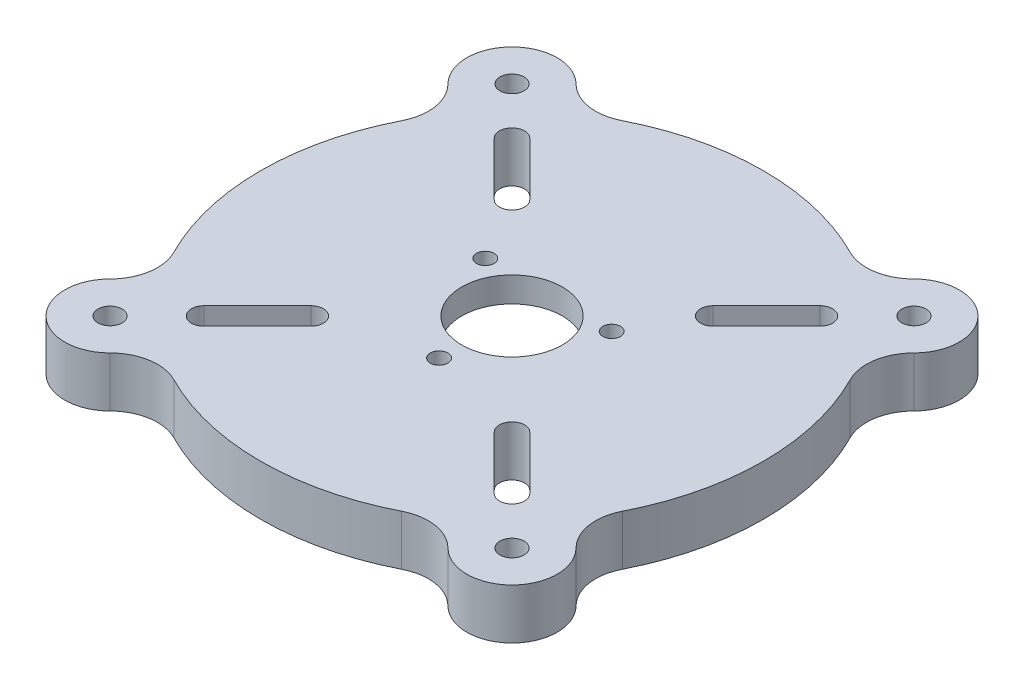
from build123d import *

# Parameters (mm, degrees)
SKETCH1_R           = 2.4
BOSS_EXTRUDE2_DEPTH = 10
SKETCH2_R           = 21.25
SKETCH2_R_2         = 1.75
SKETCH2_R_3         = 10
CUT_EXTRUDE3_DEPTH  = 5
SKETCH2_2_R         = 1.75
SKETCH2_2_R_2       = 10
CUT_EXTRUDE4_DEPTH  = 72.414284285


with BuildPart() as part:
    # Sketch1 → Boss-Extrude2 (new body)
    with BuildSketch(Plane(origin=(0, 0, 0), x_dir=(1, 0, 0), z_dir=(0, 1, 0))):
        with BuildLine():
            ThreePointArc((44.576420667, -22.648238795), (50, 0), (44.576420667, 22.648238795))
            ThreePointArc((44.576420667, 22.648238795), (43.670494672, 28.400158503), (46.315494168, 33.587572106))
            ThreePointArc((46.315494168, 33.587572106), (46.315494168, 46.315494168), (33.587572106, 46.315494168))
            ThreePointArc((33.587572106, 46.315494168), (28.400158503, 43.670494672), (22.648238795, 44.576420667))
            ThreePointArc((22.648238795, 44.576420667), (0, 50), (-22.648238795, 44.576420667))
            ThreePointArc((-22.648238795, 44.576420667), (-28.400158503, 43.670494672), (-33.587572106, 46.315494168))
            ThreePointArc((-33.587572106, 46.315494168), (-46.315494168, 46.315494168), (-46.315494168, 33.587572106))
            ThreePointArc((-46.315494168, 33.587572106), (-43.670494672, 28.400158503), (-44.576420667, 22.648238795))
            ThreePointArc((-44.576420667, 22.648238795), (-50, 0), (-44.576420667, -22.648238795))
            ThreePointArc((-44.576420667, -22.648238795), (-43.670494672, -28.400158503), (-46.315494168, -33.587572106))
            ThreePointArc((-46.315494168, -33.587572106), (-46.315494168, -46.315494168), (-33.587572106, -46.315494168))
            ThreePointArc((-33.587572106, -46.315494168), (-28.400158503, -43.670494672), (-22.648238795, -44.576420667))
            ThreePointArc((-22.648238795, -44.576420667), (0, -50), (22.648238795, -44.576420667))
            ThreePointArc((22.648238795, -44.576420667), (28.400158503, -43.670494672), (33.587572106, -46.315494168))
            ThreePointArc((33.587572106, -46.315494168), (46.315494168, -46.315494168), (46.315494168, -33.587572106))
            ThreePointArc((46.315494168, -33.587572106), (43.670494672, -28.400158503), (44.576420667, -22.648238795))
        make_face()
        with BuildLine():
            ThreePointArc((-21.767766953, -18.232233047), (-18.232233047, -18.232233047), (-18.232233047, -21.767766953))
            Line((-18.232233047, -21.767766953), (-28.838834765, -32.374368671))
            ThreePointArc((-28.838834765, -32.374368671), (-32.374368671, -32.374368671), (-32.374368671, -28.838834765))
            Line((-32.374368671, -28.838834765), (-21.767766953, -18.232233047))
        make_face(mode=Mode.SUBTRACT)
        with BuildLine():
            ThreePointArc((18.232233047, -21.767766953), (18.232233047, -18.232233047), (21.767766953, -18.232233047))
            Line((21.767766953, -18.232233047), (32.374368671, -28.838834765))
            ThreePointArc((32.374368671, -28.838834765), (32.374368671, -32.374368671), (28.838834765, -32.374368671))
            Line((28.838834765, -32.374368671), (18.232233047, -21.767766953))
        make_face(mode=Mode.SUBTRACT)
        with BuildLine():
            ThreePointArc((-18.232233047, 21.767766953), (-18.232233047, 18.232233047), (-21.767766953, 18.232233047))
            Line((-21.767766953, 18.232233047), (-32.374368671, 28.838834765))
            ThreePointArc((-32.374368671, 28.838834765), (-32.374368671, 32.374368671), (-28.838834765, 32.374368671))
            Line((-28.838834765, 32.374368671), (-18.232233047, 21.767766953))
        make_face(mode=Mode.SUBTRACT)
        with BuildLine():
            ThreePointArc((21.767766953, 18.232233047), (18.232233047, 18.232233047), (18.232233047, 21.767766953))
            Line((18.232233047, 21.767766953), (28.838834765, 32.374368671))
            ThreePointArc((28.838834765, 32.374368671), (32.374368671, 32.374368671), (32.374368671, 28.838834765))
            Line((32.374368671, 28.838834765), (21.767766953, 18.232233047))
        make_face(mode=Mode.SUBTRACT)
        with Locations((39.951533137, -39.951533137)):
            Circle(SKETCH1_R, mode=Mode.SUBTRACT)
        with Locations((-39.951533137, -39.951533137)):
            Circle(SKETCH1_R, mode=Mode.SUBTRACT)
        with Locations((-39.951533137, 39.951533137)):
            Circle(SKETCH1_R, mode=Mode.SUBTRACT)
        with Locations((39.951533137, 39.951533137)):
            Circle(SKETCH1_R, mode=Mode.SUBTRACT)
    extrude(amount=BOSS_EXTRUDE2_DEPTH)

    # Sketch2 → Cut-Extrude3 (cut)
    with BuildSketch(Plane.XZ):
        Circle(SKETCH2_R)
        with Locations((0, 14.5)):
            Circle(SKETCH2_R_2, mode=Mode.SUBTRACT)
        with Locations((12.557368355, -7.25)):
            Circle(SKETCH2_R_2, mode=Mode.SUBTRACT)
        with Locations((-12.557368355, -7.25)):
            Circle(SKETCH2_R_2, mode=Mode.SUBTRACT)
        Circle(SKETCH2_R_3, mode=Mode.SUBTRACT)
    extrude(amount=-CUT_EXTRUDE3_DEPTH, mode=Mode.SUBTRACT)

    # Sketch2_2 → Cut-Extrude4 (cut, through all)
    with BuildSketch(Plane.XZ):
        with Locations((0, 14.5)):
            Circle(SKETCH2_2_R)
        with Locations((12.557368355, -7.25)):
            Circle(SKETCH2_2_R)
        with Locations((-12.557368355, -7.25)):
            Circle(SKETCH2_2_R)
        Circle(SKETCH2_2_R_2)
    extrude(amount=-CUT_EXTRUDE4_DEPTH, mode=Mode.SUBTRACT)


solid = part.part
